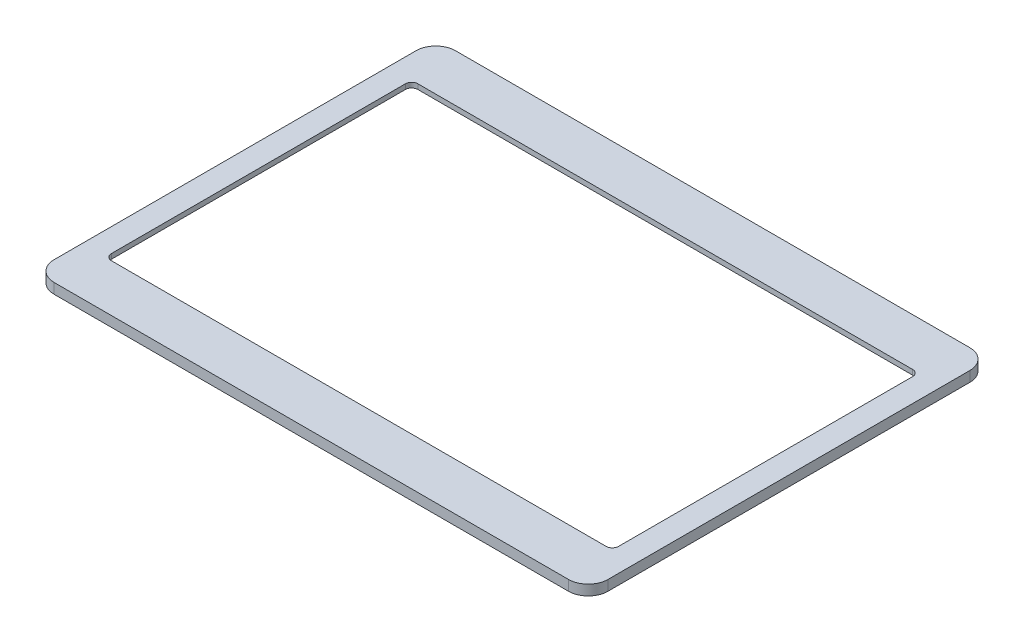
from build123d import *

# Parameters (mm, degrees)
OUTSIDE_EXTRUDE_DEPTH = 3.3
CUT_EXTRUDE4_DEPTH    = 1.7


with BuildPart() as part:
    # Sketch1 → Outside-extrude (new body)
    with BuildSketch(Plane(origin=(0, 0, 0), x_dir=(1, 0, 0), z_dir=(0, 1, 0))):
        with BuildLine():
            Line((-82.65, 64.5), (82.65, 64.5))
            ThreePointArc((82.65, 64.5), (87.140128061, 62.640128061), (89, 58.15))
            Line((89, 58.15), (89, -58.15))
            ThreePointArc((89, -58.15), (87.140128061, -62.640128061), (82.65, -64.5))
            Line((82.65, -64.5), (-82.65, -64.5))
            ThreePointArc((-82.65, -64.5), (-87.140128061, -62.640128061), (-89, -58.15))
            Line((-89, -58.15), (-89, 58.15))
            ThreePointArc((-89, 58.15), (-87.140128061, 62.640128061), (-82.65, 64.5))
        make_face()
        with BuildLine():
            Line((-79.5, 49.25), (79.5, 49.25))
            ThreePointArc((79.5, 49.25), (80.914213562, 48.664213562), (81.5, 47.25))
            Line((81.5, 47.25), (81.5, -47.25))
            ThreePointArc((81.5, -47.25), (80.914213562, -48.664213562), (79.5, -49.25))
            Line((79.5, -49.25), (-79.5, -49.25))
            ThreePointArc((-79.5, -49.25), (-80.914213562, -48.664213562), (-81.5, -47.25))
            Line((-81.5, -47.25), (-81.5, 47.25))
            ThreePointArc((-81.5, 47.25), (-80.914213562, 48.664213562), (-79.5, 49.25))
        make_face(mode=Mode.SUBTRACT)
    extrude(amount=OUTSIDE_EXTRUDE_DEPTH)

    # Sketch2 → Cut-Extrude4 (cut)
    with BuildSketch(Plane(origin=(0, 0, 0), x_dir=(1, 0, 0), z_dir=(0, 1, 0))):
        Polygon((-15.5, -58.5), (-15.5, -60.5), (15.5, -60.5), (15.5, -58.75), (85.5, -58.75), (85.5, 53.5), (-85.5, 53.5), (-85.5, -58.5), align=None)
    extrude(amount=CUT_EXTRUDE4_DEPTH, mode=Mode.SUBTRACT)


solid = part.part
